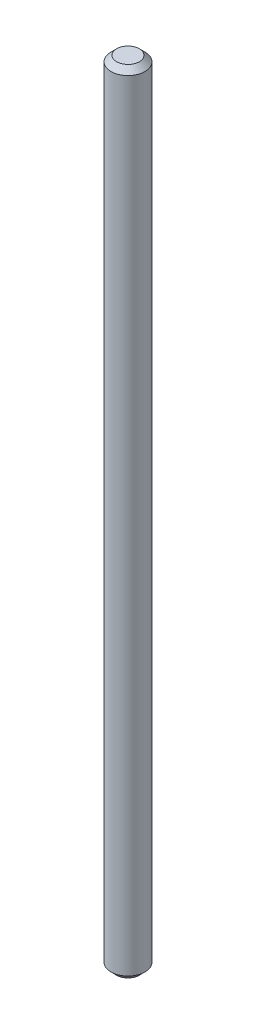
from build123d import *

# Parameters (mm, degrees)
SKETCH2_R           = 1.5
BOSS_EXTRUDE1_DEPTH = 70
CHAMFER1_SIZE       = 0.5


with BuildPart() as part:
    # Sketch2 → Boss-Extrude1 (new body)
    with BuildSketch(Plane(origin=(0, 0, 0), x_dir=(1, 0, 0), z_dir=(0, 1, 0))):
        Circle(SKETCH2_R)
    extrude(amount=BOSS_EXTRUDE1_DEPTH)

    # Chamfer1
    chamfer1_edges = [part.edges().sort_by_distance(p)[0] for p in [
        (-1.5, 0, 0),
        (-1.5, 70, 0),
    ]]
    chamfer(chamfer1_edges, length=CHAMFER1_SIZE)


solid = part.part
